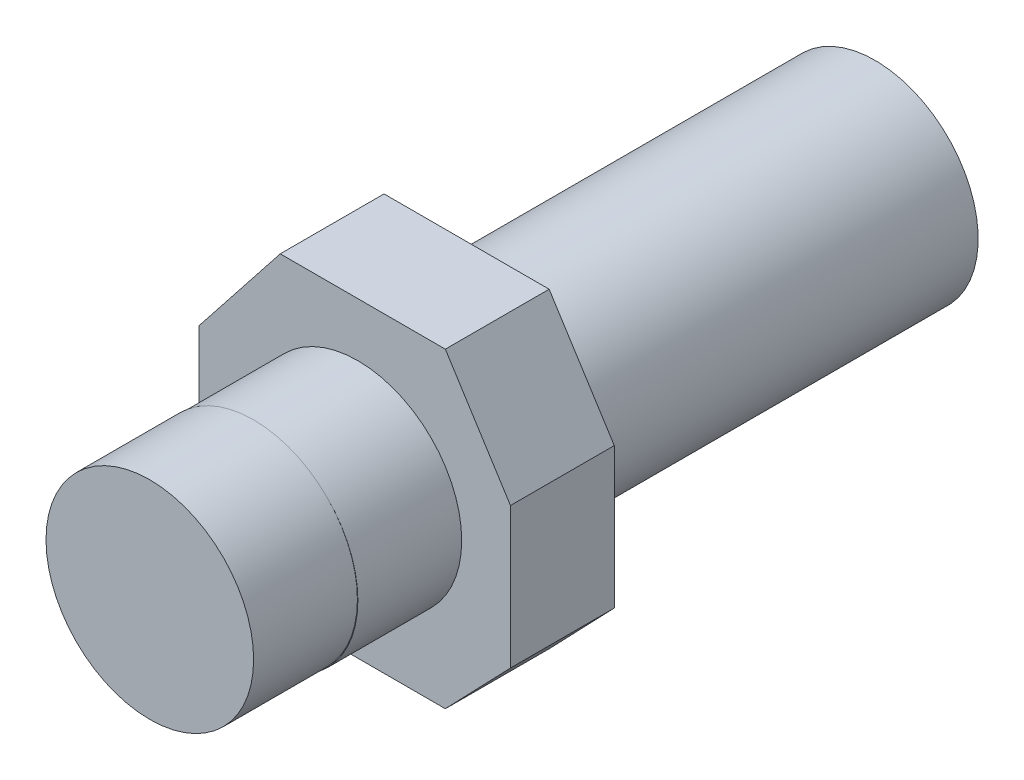
from build123d import *

# Parameters (mm, degrees)
BOSS_EXTRUDE1_DEPTH = 10
SKETCH2_R           = 10
BOSS_EXTRUDE2_DEPTH = 10
SKETCH3_R           = 10
BOSS_EXTRUDE3_DEPTH = 10
SKETCH4_R           = 9.92496084
BOSS_EXTRUDE4_DEPTH = 40


with BuildPart() as part:
    # Sketch1 → Boss-Extrude1 (new body)
    with BuildSketch(Plane.XY):
        Polygon((3.215110596, 16.166425121), (19.120786924, 16.166425121), (25.392646828, 6.257971014), (25.392646828, -7.300966184), (19.120786924, -13.833574879), (3.215110596, -13.833574879), (-4.607353172, -7.300966184), (-4.607353172, 6.257971014), align=None)
    extrude(amount=BOSS_EXTRUDE1_DEPTH)

    # Sketch2 → Boss-Extrude2 (add)
    with BuildSketch(Plane.XY.offset(10)):
        with Locations((10.695865166, 0.993157499)):
            Circle(SKETCH2_R)
    extrude(amount=BOSS_EXTRUDE2_DEPTH)

    # Sketch3 → Boss-Extrude3 (add)
    with BuildSketch(Plane.XY.offset(20)):
        with Locations((10.65254826, 1.036474405)):
            Circle(SKETCH3_R)
    extrude(amount=BOSS_EXTRUDE3_DEPTH)

    # Sketch4 → Boss-Extrude4 (add)
    with BuildSketch(Plane(origin=(0, 0, 0), x_dir=(-1, 0, 0), z_dir=(0, 0, -1))):
        with Locations((-10.522597544, 1.036474405)):
            Circle(SKETCH4_R)
    extrude(amount=BOSS_EXTRUDE4_DEPTH)


solid = part.part
